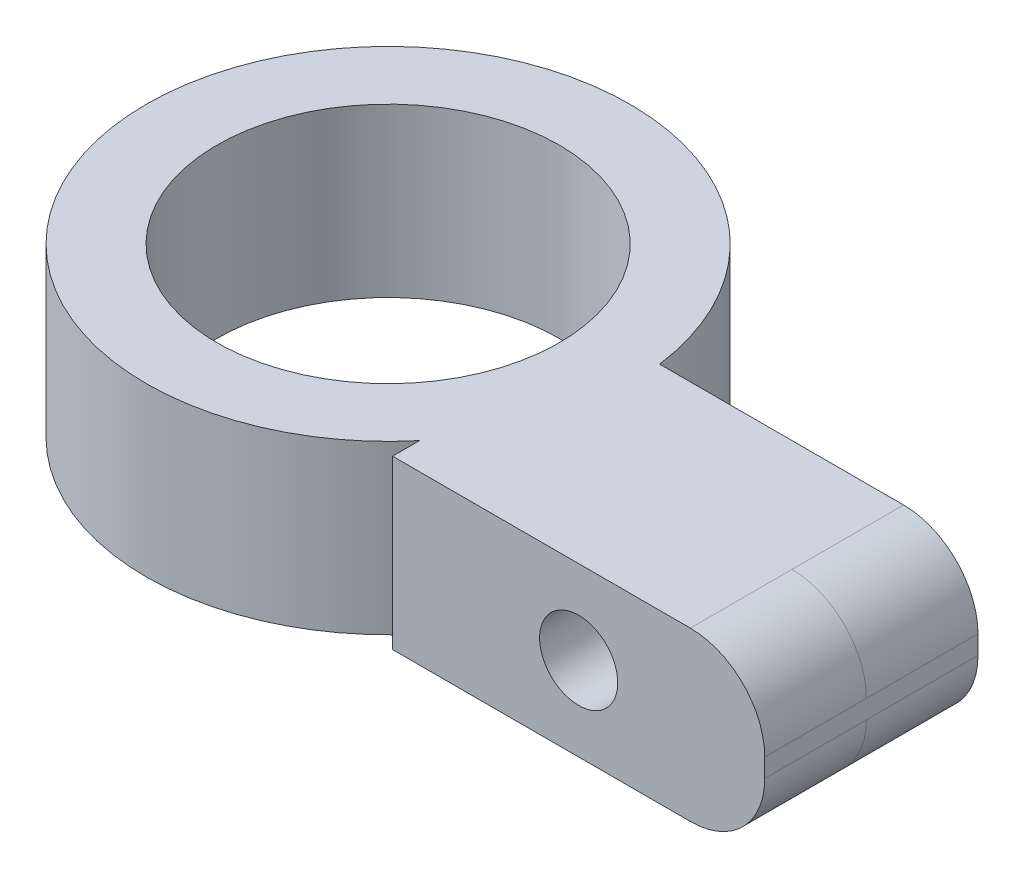
from build123d import *

# Parameters (mm, degrees)
SKETCH1_W           = 10
SKETCH1_H           = 4.5
BOSS_EXTRUDE1_DEPTH = 3
FILLET1_R           = 2
SKETCH3_R           = 6.5
BOSS_EXTRUDE2_DEPTH = 2.25
SKETCH4_R           = 4.6
CUT_EXTRUDE1_DEPTH  = 5.5
SKETCH8_W           = 10
SKETCH8_H           = 4.5
BOSS_EXTRUDE5_DEPTH = 2.73
SKETCH9_R           = 1.05
CUT_EXTRUDE2_DEPTH  = 3
FILLET3_R           = 2


with BuildPart() as part:
    # Sketch1 → Boss-Extrude1 (new body)
    with BuildSketch(Plane.XY):
        Rectangle(SKETCH1_W, SKETCH1_H)
    extrude(amount=BOSS_EXTRUDE1_DEPTH)

    # Fillet1
    fillet1_edges = [part.edges().sort_by_distance(p)[0] for p in [
        (5, 2.25, 1.5),
        (5, -2.25, 1.5),
    ]]
    fillet(fillet1_edges, radius=FILLET1_R)



with BuildPart() as body_2:
    # Sketch3 → Boss-Extrude2 (new body, symmetric)
    with BuildSketch(Plane(origin=(0, 0, 0), x_dir=(1, 0, 0), z_dir=(0, 1, 0))):
        with Locations((-10, -0.85)):
            Circle(SKETCH3_R)
    extrude(amount=BOSS_EXTRUDE2_DEPTH, both=True)

    # Sketch4 → Cut-Extrude1 (cut, through all)
    with BuildSketch(Plane.XZ.offset(2.25)):
        with Locations((-10, 0.85)):
            Circle(SKETCH4_R)
    extrude(amount=-CUT_EXTRUDE1_DEPTH, mode=Mode.SUBTRACT)


with BuildPart() as part_1:
    add(part.part)

    add(body_2.part)  # Boss-Extrude5 merges body 2
    # Sketch8 → Boss-Extrude5 (add)
    with BuildSketch(Plane.XY.offset(3)):
        Rectangle(SKETCH8_W, SKETCH8_H)
    extrude(amount=BOSS_EXTRUDE5_DEPTH)

    # Sketch9 → Cut-Extrude2 (cut)
    with BuildSketch(Plane.XY.offset(5.73)):
        Circle(SKETCH9_R)
    extrude(amount=-CUT_EXTRUDE2_DEPTH, mode=Mode.SUBTRACT)

    # Fillet3
    fillet3_edges = [part_1.edges().sort_by_distance(p)[0] for p in [
        (5, 2.25, 4.365),
        (5, -2.25, 4.365),
    ]]
    fillet(fillet3_edges, radius=FILLET3_R)


solid = part_1.part
